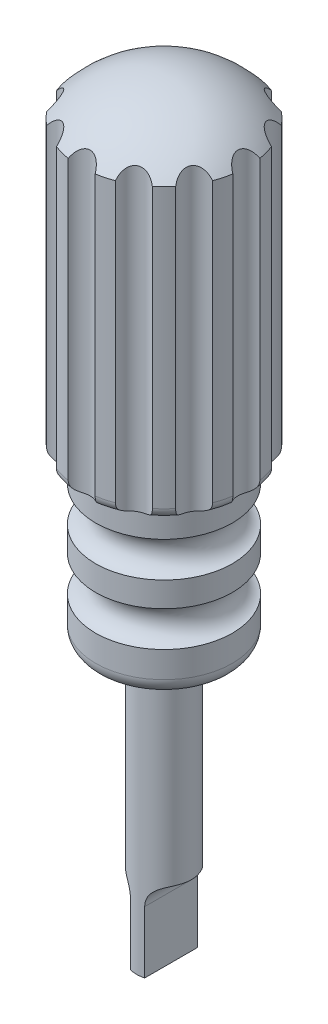
from build123d import *

# Parameters (mm, degrees)
SKETCH_4_R               = 3.3
FILLET_1_R               = 2
FILLET_2_R               = 3
CUT_EXTRUDE_START        = -1
SKETCH_6_R               = 2.75
CUT_EXTRUDE_2_DEPTH      = 142
PATTERN_CIRCULAR_1_COUNT = 12
CUT_EXTRUDE_3_DEPTH      = 16.048819288
CUT_EXTRUDE_3_DEPTH_BACK = 16.048819288


with BuildPart() as part:
    # 스케치3 → 회전1 (revolve)
    with BuildSketch(Plane.XY):
        with BuildLine():
            Line((-15.25, 133), (-15.25, 80))
            Line((-15.25, 80), (-12.5, 80))
            Line((-12.5, 80), (-12.5, 50))
            Line((-12.5, 50), (-5, 50))
            Line((-5, 50), (-5, 0))
            Line((-5, 0), (0, 0))
            Line((0, 0), (0, 140))
            ThreePointArc((0, 140), (-8.389912097, 138.16641564), (-15.25, 133))
        make_face()
    revolve(axis=Axis((0, 140, 0), (0, -1, 0)))

    # 스케치4 → 컷-회전1 (revolve, cut)
    with BuildSketch(Plane.XY):
        with Locations((13.2, 61)):
            Circle(SKETCH_4_R)
        with Locations((13.2, 72)):
            Circle(SKETCH_4_R)
    revolve(axis=Axis((0, 80, 0), (0, 1, 0)), mode=Mode.SUBTRACT)

    # 필렛1
    fillet_1_edges = [part.edges().sort_by_distance(p)[0] for p in [
        (15.25, 80, 0),
    ]]
    fillet(fillet_1_edges, radius=FILLET_1_R)

    # 필렛2
    fillet_2_edges = [part.edges().sort_by_distance(p)[0] for p in [
        (12.5, 50, 0),
    ]]
    fillet(fillet_2_edges, radius=FILLET_2_R)

    # 스케치6 → 컷-돌출2 (cut)
    with BuildSketch(Plane(origin=(0, 0, 0), x_dir=(1, 0, 0), z_dir=(0, 1, 0)).offset(CUT_EXTRUDE_START)):
        with Locations((0, 16.26)):
            Circle(SKETCH_6_R)
    cut_extrude_2 = extrude(amount=CUT_EXTRUDE_2_DEPTH, mode=Mode.SUBTRACT)

    # 원형 패턴1: 컷-돌출2 ×12 about axis
    pattern_circular_1_axis = Axis((0, 0, 0), (0, 1, 0))
    for i in range(1, PATTERN_CIRCULAR_1_COUNT):
        add(cut_extrude_2.rotate(pattern_circular_1_axis, i * 360 / PATTERN_CIRCULAR_1_COUNT), mode=Mode.SUBTRACT)

    # 스케치7 → 컷-돌출3 (cut, two sides)
    with BuildSketch(Plane.XY) as cut_extrude_3_sk:
        with BuildLine():
            Line((1.3, 0), (1.3, 11.3))
            ThreePointArc((1.3, 11.3), (2.38370491, 13.91629509), (5, 15))
            Line((5, 15), (11.3, 15))
            Line((11.3, 15), (11.3, 0))
            Line((11.3, 0), (1.3, 0))
        make_face()
        with BuildLine():
            Line((-11.3, 0), (-1.3, 0))
            Line((-1.3, 0), (-1.3, 11.3))
            ThreePointArc((-1.3, 11.3), (-2.38370491, 13.91629509), (-5, 15))
            Line((-5, 15), (-11.3, 15))
            Line((-11.3, 15), (-11.3, 0))
        make_face()
    extrude(amount=CUT_EXTRUDE_3_DEPTH, mode=Mode.SUBTRACT)
    extrude(cut_extrude_3_sk.sketch, amount=-CUT_EXTRUDE_3_DEPTH_BACK, mode=Mode.SUBTRACT)


solid = part.part
